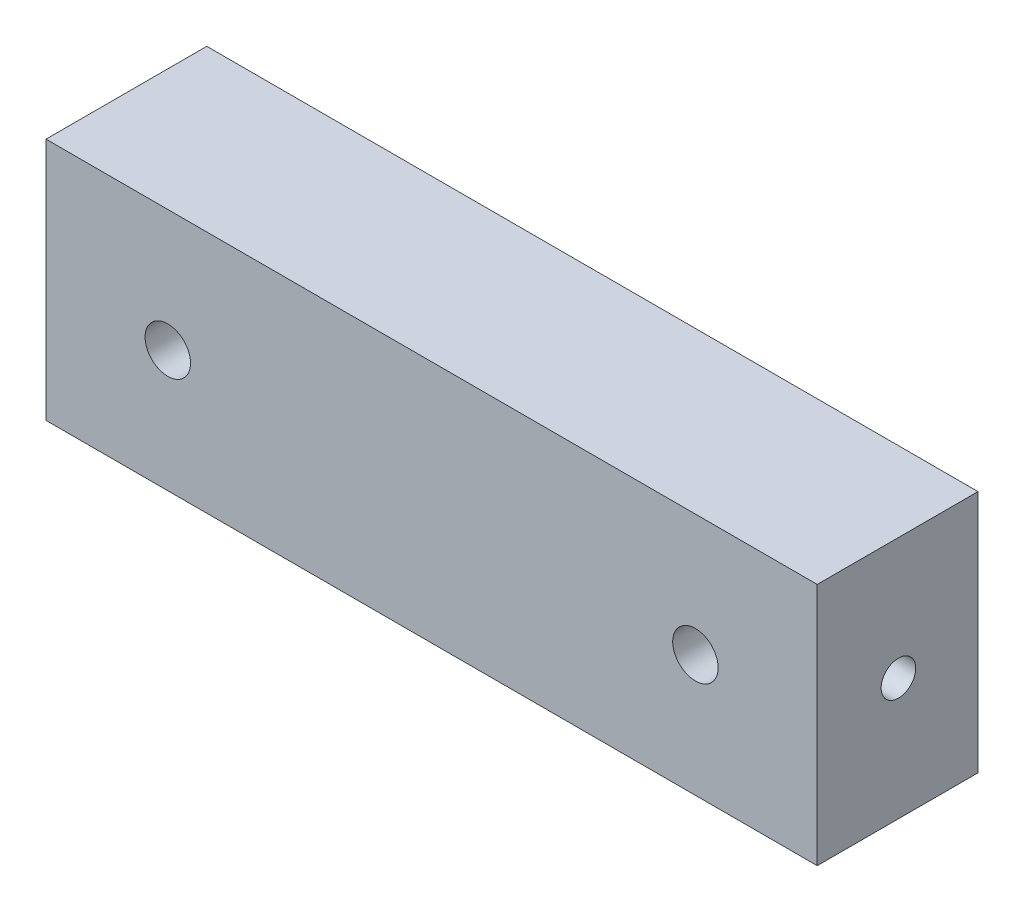
from build123d import *

# Parameters (mm, degrees)
SKETCH1_W                 = 60.3123
SKETCH1_H                 = 19.05
EXTRUDE1_DEPTH            = 12.573
SKETCH2_R                 = 1.778
CUT_EXTRUDE1_DEPTH        = 13.573
F_6_32_TAPPED_HOLE1_D     = 2.7051
F_6_32_TAPPED_HOLE1_DEPTH = 9.525
F_6_32_TAPPED_HOLE1_TIP   = 0.81269403
F_6_32_TAPPED_HOLE2_D     = 2.7051
F_6_32_TAPPED_HOLE2_DEPTH = 9.525
F_6_32_TAPPED_HOLE2_TIP   = 0.81269403


with BuildPart() as part:
    # Sketch1 → Extrude1 (new body)
    with BuildSketch(Plane.XY):
        with Locations((30.15615, 9.525)):
            Rectangle(SKETCH1_W, SKETCH1_H)
    extrude(amount=EXTRUDE1_DEPTH)

    # Sketch2 → Cut-Extrude1 (cut, through all)
    with BuildSketch(Plane.XY.offset(12.573)):
        with Locations((9.525, 9.525)):
            Circle(SKETCH2_R)
        with Locations((50.7873, 9.525)):
            Circle(SKETCH2_R)
    extrude(amount=-CUT_EXTRUDE1_DEPTH, mode=Mode.SUBTRACT)

    # #6-32 Tapped Hole1
    with Locations(Plane.ZY):
        with Locations((6.223, 9.525)):
            Hole(F_6_32_TAPPED_HOLE1_D / 2, depth=F_6_32_TAPPED_HOLE1_DEPTH)
            with Locations((0, 0, -(F_6_32_TAPPED_HOLE1_DEPTH + F_6_32_TAPPED_HOLE1_TIP / 2))):  # 118° drill point
                Cone(0, F_6_32_TAPPED_HOLE1_D / 2, F_6_32_TAPPED_HOLE1_TIP, mode=Mode.SUBTRACT)

    # #6-32 Tapped Hole2
    with Locations(Plane(origin=(60.3123, 0, 0), x_dir=(0, 0, -1), z_dir=(1, 0, 0))):
        with Locations((-6.223, 9.525)):
            Hole(F_6_32_TAPPED_HOLE2_D / 2, depth=F_6_32_TAPPED_HOLE2_DEPTH)
            with Locations((0, 0, -(F_6_32_TAPPED_HOLE2_DEPTH + F_6_32_TAPPED_HOLE2_TIP / 2))):  # 118° drill point
                Cone(0, F_6_32_TAPPED_HOLE2_D / 2, F_6_32_TAPPED_HOLE2_TIP, mode=Mode.SUBTRACT)


solid = part.part
